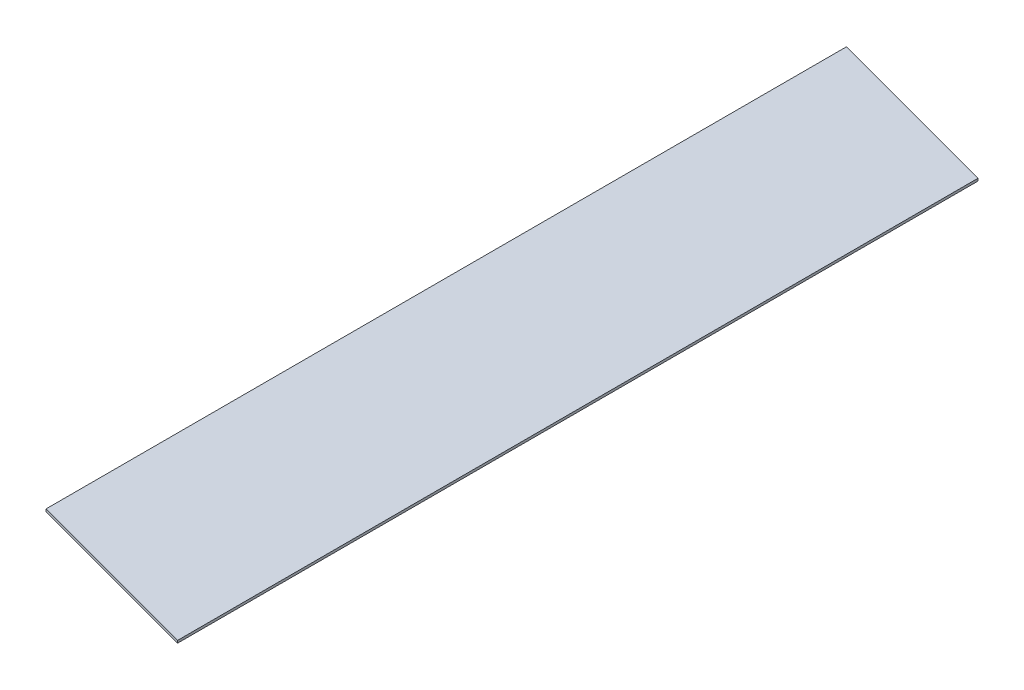
from build123d import *

# Parameters (mm, degrees)
SKETCH1_W           = 185.42
SKETCH1_H           = 826.262
BOSS_EXTRUDE1_DEPTH = 2.54
CUT_EXTRUDE1_DEPTH  = 2.54
BOSS_EXTRUDE3_DEPTH = 2.54


with BuildPart() as part:
    # Sketch1 → Boss-Extrude1 (new body)
    with BuildSketch(Plane(origin=(0, 0, 0), x_dir=(1, 0, 0), z_dir=(0, 1, 0))):
        with Locations((2.261219512, -330.596487805)):
            Rectangle(SKETCH1_W, SKETCH1_H)
    extrude(amount=BOSS_EXTRUDE1_DEPTH)

    # Sketch2 → Cut-Extrude1 (cut)
    with BuildSketch(Plane(origin=(0, 2.54, 0), x_dir=(1, 0, 0), z_dir=(0, 1, 0))):
        Polygon((94.971219512, -743.727487805), (-90.448780488, -694.044348544), (-90.448780488, -743.727487805), align=None)
    extrude(amount=-CUT_EXTRUDE1_DEPTH, mode=Mode.SUBTRACT)

    # Sketch3 → Boss-Extrude3 (add)
    with BuildSketch(Plane.XZ):
        Polygon((-90.448780488, -82.534512195), (-90.448780488, -132.217651456), (94.971219512, -82.534512195), align=None)
    extrude(amount=-BOSS_EXTRUDE3_DEPTH)


solid = part.part
